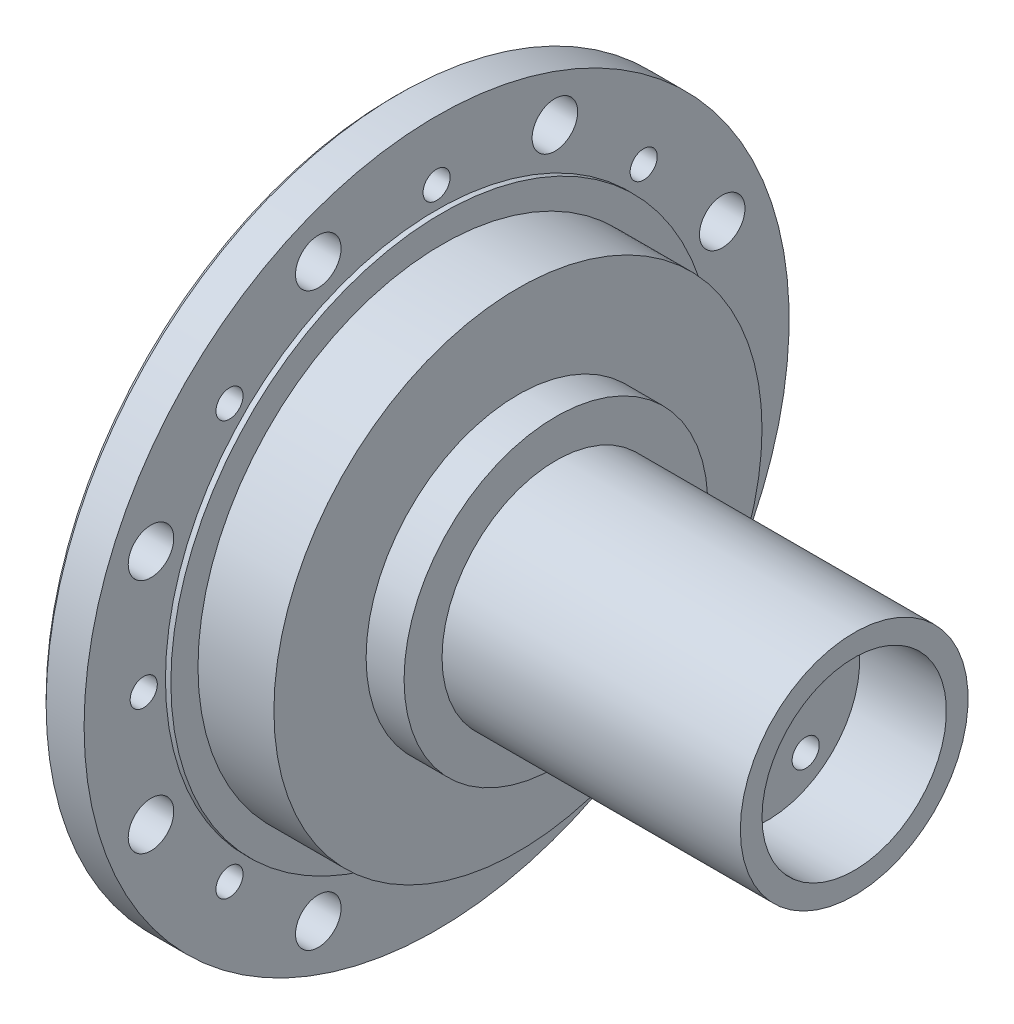
from build123d import *

# Parameters (mm, degrees)
SKETCH2_R          = 32.5
CUT_EXTRUDE1_DEPTH = 3
SKETCH3_R          = 1.25
CUT_EXTRUDE2_DEPTH = 12
CUT_EXTRUDE3_REACH = 44.5
SKETCH4_R          = 1.25
SKETCH4_R_2        = 2.1
CHAMFER1_SIZE      = 0.5
CHAMFER2_SIZE      = 0.5


with BuildPart() as part:
    # Sketch1 → Revolve1 (revolve)
    with BuildSketch(Plane.YX):
        Polygon((-32.5, -4.5), (-32.5, -0.5), (-25, -0.5), (-25, 0), (-22.5, 0), (-22.5, 7), (-14, 7), (-14, 10.5), (-10.5, 10.5), (-10.5, 38), (-8.5, 38), (-8.5, 30), (0, 30), (0, 9.5), (-8, 9.5), (-8, 4.5), (-20, 4.5), (-20, -7.5), (-24, -7.5), (-24, -4.5), align=None)
    revolve(axis=Axis((0, 0, 0), (1, 0, 0)))

    # Sketch2 → Cut-Extrude1 (cut)
    with BuildSketch(Plane.ZY.offset(7.5)):
        Circle(SKETCH2_R)
        with BuildLine():
            Line((-8.94427191, 22), (8.94427191, 22))
            ThreePointArc((8.94427191, 22), (9.598925581, 21.927700219), (10.22202504, 21.714285714))
            ThreePointArc((10.22202504, 21.714285714), (16.970562748, 16.970562748), (21.714285714, 10.22202504))
            ThreePointArc((21.714285714, 10.22202504), (21.927700219, 9.598925581), (22, 8.94427191))
            Line((22, 8.94427191), (22, -8.94427191))
            ThreePointArc((22, -8.94427191), (21.927700219, -9.598925581), (21.714285714, -10.22202504))
            ThreePointArc((21.714285714, -10.22202504), (16.970562748, -16.970562748), (10.22202504, -21.714285714))
            ThreePointArc((10.22202504, -21.714285714), (9.598925581, -21.927700219), (8.94427191, -22))
            Line((8.94427191, -22), (-8.94427191, -22))
            ThreePointArc((-8.94427191, -22), (-9.598925581, -21.927700219), (-10.22202504, -21.714285714))
            ThreePointArc((-10.22202504, -21.714285714), (-16.970562748, -16.970562748), (-21.714285714, -10.22202504))
            ThreePointArc((-21.714285714, -10.22202504), (-21.927700219, -9.598925581), (-22, -8.94427191))
            Line((-22, -8.94427191), (-22, 8.94427191))
            ThreePointArc((-22, 8.94427191), (-21.927700219, 9.598925581), (-21.714285714, 10.22202504))
            ThreePointArc((-21.714285714, 10.22202504), (-16.970562748, 16.970562748), (-10.22202504, 21.714285714))
            ThreePointArc((-10.22202504, 21.714285714), (-9.598925581, 21.927700219), (-8.94427191, 22))
        make_face(mode=Mode.SUBTRACT)
    extrude(amount=-CUT_EXTRUDE1_DEPTH, mode=Mode.SUBTRACT)

    # Sketch3 → Cut-Extrude2 (cut)
    with BuildSketch(Plane(origin=(30, 0, 0), x_dir=(0, 0, -1), z_dir=(1, 0, 0))):
        with Locations((0, 6)):
            Circle(SKETCH3_R)
        with Locations((5.706339098, 1.854101966)):
            Circle(SKETCH3_R)
        with Locations((3.526711514, -4.854101966)):
            Circle(SKETCH3_R)
        with Locations((-3.526711514, -4.854101966)):
            Circle(SKETCH3_R)
        with Locations((-5.706339098, 1.854101966)):
            Circle(SKETCH3_R)
    extrude(amount=-CUT_EXTRUDE2_DEPTH, mode=Mode.SUBTRACT)

    # Sketch4 → Cut-Extrude3 (cut, up to next)
    with BuildSketch(Plane.ZY.offset(4.5), mode=Mode.PRIVATE) as cut_extrude3_sk1:
        with Locations((0, 27)):
            Circle(SKETCH4_R)
    cut_extrude3_tool1 = extrude(cut_extrude3_sk1.sketch, amount=-CUT_EXTRUDE3_REACH, mode=Mode.PRIVATE) & part.part
    add(cut_extrude3_tool1.solids().sort_by_distance((-4.5, 27, 0))[0], mode=Mode.SUBTRACT)
    # Sketch4 → Cut-Extrude3 (cut, up to next)
    with BuildSketch(Plane.ZY.offset(4.5), mode=Mode.PRIVATE) as cut_extrude3_sk2:
        with Locations((10.906477822, 26.330566677)):
            Circle(SKETCH4_R_2)
    cut_extrude3_tool2 = extrude(cut_extrude3_sk2.sketch, amount=-CUT_EXTRUDE3_REACH, mode=Mode.PRIVATE) & part.part
    add(cut_extrude3_tool2.solids().sort_by_distance((-4.5, 26.330567, 10.906478))[0], mode=Mode.SUBTRACT)
    # Sketch4 → Cut-Extrude3 (cut, up to next)
    with BuildSketch(Plane.ZY.offset(4.5), mode=Mode.PRIVATE) as cut_extrude3_sk3:
        with Locations((19.091883092, 19.091883092)):
            Circle(SKETCH4_R)
    cut_extrude3_tool3 = extrude(cut_extrude3_sk3.sketch, amount=-CUT_EXTRUDE3_REACH, mode=Mode.PRIVATE) & part.part
    add(cut_extrude3_tool3.solids().sort_by_distance((-4.5, 19.091883, 19.091883))[0], mode=Mode.SUBTRACT)
    # Sketch4 → Cut-Extrude3 (cut, up to next)
    with BuildSketch(Plane.ZY.offset(4.5), mode=Mode.PRIVATE) as cut_extrude3_sk4:
        with Locations((26.330566677, 10.906477822)):
            Circle(SKETCH4_R_2)
    cut_extrude3_tool4 = extrude(cut_extrude3_sk4.sketch, amount=-CUT_EXTRUDE3_REACH, mode=Mode.PRIVATE) & part.part
    add(cut_extrude3_tool4.solids().sort_by_distance((-4.5, 10.906478, 26.330567))[0], mode=Mode.SUBTRACT)
    # Sketch4 → Cut-Extrude3 (cut, up to next)
    with BuildSketch(Plane.ZY.offset(4.5), mode=Mode.PRIVATE) as cut_extrude3_sk5:
        with Locations((27, 0)):
            Circle(SKETCH4_R)
    cut_extrude3_tool5 = extrude(cut_extrude3_sk5.sketch, amount=-CUT_EXTRUDE3_REACH, mode=Mode.PRIVATE) & part.part
    add(cut_extrude3_tool5.solids().sort_by_distance((-4.5, 0, 27))[0], mode=Mode.SUBTRACT)
    # Sketch4 → Cut-Extrude3 (cut, up to next)
    with BuildSketch(Plane.ZY.offset(4.5), mode=Mode.PRIVATE) as cut_extrude3_sk6:
        with Locations((26.330566677, -10.906477822)):
            Circle(SKETCH4_R_2)
    cut_extrude3_tool6 = extrude(cut_extrude3_sk6.sketch, amount=-CUT_EXTRUDE3_REACH, mode=Mode.PRIVATE) & part.part
    add(cut_extrude3_tool6.solids().sort_by_distance((-4.5, -10.906478, 26.330567))[0], mode=Mode.SUBTRACT)
    # Sketch4 → Cut-Extrude3 (cut, up to next)
    with BuildSketch(Plane.ZY.offset(4.5), mode=Mode.PRIVATE) as cut_extrude3_sk7:
        with Locations((19.091883092, -19.091883092)):
            Circle(SKETCH4_R)
    cut_extrude3_tool7 = extrude(cut_extrude3_sk7.sketch, amount=-CUT_EXTRUDE3_REACH, mode=Mode.PRIVATE) & part.part
    add(cut_extrude3_tool7.solids().sort_by_distance((-4.5, -19.091883, 19.091883))[0], mode=Mode.SUBTRACT)
    # Sketch4 → Cut-Extrude3 (cut, up to next)
    with BuildSketch(Plane.ZY.offset(4.5), mode=Mode.PRIVATE) as cut_extrude3_sk8:
        with Locations((10.906477822, -26.330566677)):
            Circle(SKETCH4_R_2)
    cut_extrude3_tool8 = extrude(cut_extrude3_sk8.sketch, amount=-CUT_EXTRUDE3_REACH, mode=Mode.PRIVATE) & part.part
    add(cut_extrude3_tool8.solids().sort_by_distance((-4.5, -26.330567, 10.906478))[0], mode=Mode.SUBTRACT)
    # Sketch4 → Cut-Extrude3 (cut, up to next)
    with BuildSketch(Plane.ZY.offset(4.5), mode=Mode.PRIVATE) as cut_extrude3_sk9:
        with Locations((0, -27)):
            Circle(SKETCH4_R)
    cut_extrude3_tool9 = extrude(cut_extrude3_sk9.sketch, amount=-CUT_EXTRUDE3_REACH, mode=Mode.PRIVATE) & part.part
    add(cut_extrude3_tool9.solids().sort_by_distance((-4.5, -27, 0))[0], mode=Mode.SUBTRACT)
    # Sketch4 → Cut-Extrude3 (cut, up to next)
    with BuildSketch(Plane.ZY.offset(4.5), mode=Mode.PRIVATE) as cut_extrude3_sk10:
        with Locations((-10.906477822, -26.330566677)):
            Circle(SKETCH4_R_2)
    cut_extrude3_tool10 = extrude(cut_extrude3_sk10.sketch, amount=-CUT_EXTRUDE3_REACH, mode=Mode.PRIVATE) & part.part
    add(cut_extrude3_tool10.solids().sort_by_distance((-4.5, -26.330567, -10.906478))[0], mode=Mode.SUBTRACT)
    # Sketch4 → Cut-Extrude3 (cut, up to next)
    with BuildSketch(Plane.ZY.offset(4.5), mode=Mode.PRIVATE) as cut_extrude3_sk11:
        with Locations((-19.091883092, -19.091883092)):
            Circle(SKETCH4_R)
    cut_extrude3_tool11 = extrude(cut_extrude3_sk11.sketch, amount=-CUT_EXTRUDE3_REACH, mode=Mode.PRIVATE) & part.part
    add(cut_extrude3_tool11.solids().sort_by_distance((-4.5, -19.091883, -19.091883))[0], mode=Mode.SUBTRACT)
    # Sketch4 → Cut-Extrude3 (cut, up to next)
    with BuildSketch(Plane.ZY.offset(4.5), mode=Mode.PRIVATE) as cut_extrude3_sk12:
        with Locations((-26.330566677, -10.906477822)):
            Circle(SKETCH4_R_2)
    cut_extrude3_tool12 = extrude(cut_extrude3_sk12.sketch, amount=-CUT_EXTRUDE3_REACH, mode=Mode.PRIVATE) & part.part
    add(cut_extrude3_tool12.solids().sort_by_distance((-4.5, -10.906478, -26.330567))[0], mode=Mode.SUBTRACT)
    # Sketch4 → Cut-Extrude3 (cut, up to next)
    with BuildSketch(Plane.ZY.offset(4.5), mode=Mode.PRIVATE) as cut_extrude3_sk13:
        with Locations((-27, 0)):
            Circle(SKETCH4_R)
    cut_extrude3_tool13 = extrude(cut_extrude3_sk13.sketch, amount=-CUT_EXTRUDE3_REACH, mode=Mode.PRIVATE) & part.part
    add(cut_extrude3_tool13.solids().sort_by_distance((-4.5, 0, -27))[0], mode=Mode.SUBTRACT)
    # Sketch4 → Cut-Extrude3 (cut, up to next)
    with BuildSketch(Plane.ZY.offset(4.5), mode=Mode.PRIVATE) as cut_extrude3_sk14:
        with Locations((-26.330566677, 10.906477822)):
            Circle(SKETCH4_R_2)
    cut_extrude3_tool14 = extrude(cut_extrude3_sk14.sketch, amount=-CUT_EXTRUDE3_REACH, mode=Mode.PRIVATE) & part.part
    add(cut_extrude3_tool14.solids().sort_by_distance((-4.5, 10.906478, -26.330567))[0], mode=Mode.SUBTRACT)
    # Sketch4 → Cut-Extrude3 (cut, up to next)
    with BuildSketch(Plane.ZY.offset(4.5), mode=Mode.PRIVATE) as cut_extrude3_sk15:
        with Locations((-19.091883092, 19.091883092)):
            Circle(SKETCH4_R)
    cut_extrude3_tool15 = extrude(cut_extrude3_sk15.sketch, amount=-CUT_EXTRUDE3_REACH, mode=Mode.PRIVATE) & part.part
    add(cut_extrude3_tool15.solids().sort_by_distance((-4.5, 19.091883, -19.091883))[0], mode=Mode.SUBTRACT)
    # Sketch4 → Cut-Extrude3 (cut, up to next)
    with BuildSketch(Plane.ZY.offset(4.5), mode=Mode.PRIVATE) as cut_extrude3_sk16:
        with Locations((-10.906477822, 26.330566677)):
            Circle(SKETCH4_R_2)
    cut_extrude3_tool16 = extrude(cut_extrude3_sk16.sketch, amount=-CUT_EXTRUDE3_REACH, mode=Mode.PRIVATE) & part.part
    add(cut_extrude3_tool16.solids().sort_by_distance((-4.5, 26.330567, -10.906478))[0], mode=Mode.SUBTRACT)

    # Chamfer1
    chamfer1_edges = [part.edges().sort_by_distance(p)[0] for p in [
        (-7.5, 16.970562748, 16.970562748),
        (-7.5, 20, 0),
        (-7.5, 16.970562748, -16.970562748),
        (-7.5, -16.970562748, -16.970562748),
        (-7.5, -16.970562748, 16.970562748),
        (-7.5, -9.598925581, 21.927700219),
        (-7.5, -21.927700219, 9.598925581),
        (-7.5, -22, 0),
        (-7.5, -21.927700219, -9.598925581),
        (-7.5, -9.598925581, -21.927700219),
        (-7.5, 0, -22),
        (-7.5, 9.598925581, -21.927700219),
        (-7.5, 21.927700219, -9.598925581),
        (-7.5, 22, 0),
        (-7.5, 21.927700219, 9.598925581),
        (-7.5, 9.598925581, 21.927700219),
        (-7.5, 0, 22),
    ]]
    chamfer(chamfer1_edges, length=CHAMFER1_SIZE)

    # Chamfer2
    chamfer2_edges = [part.edges().sort_by_distance(p)[0] for p in [
        (-4.5, 32.5, 0),
    ]]
    chamfer(chamfer2_edges, length=CHAMFER2_SIZE)


solid = part.part
